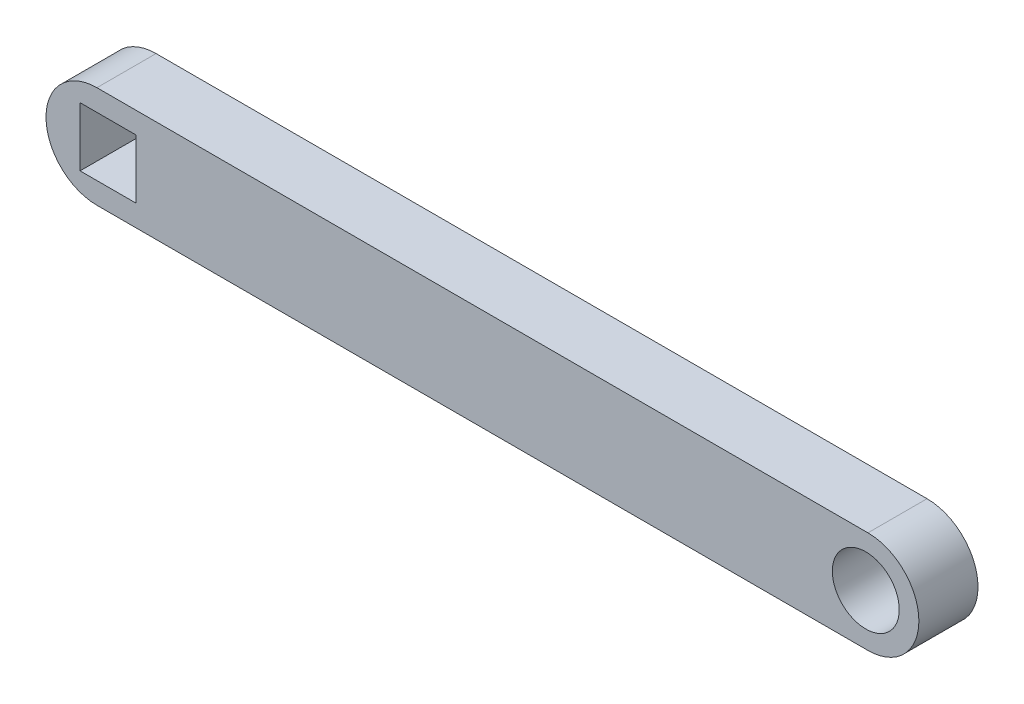
from build123d import *

# Parameters (mm, degrees)
BOSS_EXTRUDE1_DEPTH     = 3.5
SKETCH3_R               = 3.960739879
CUT_EXTRUDE2_DEPTH      = 4.5
CUT_EXTRUDE2_DEPTH_BACK = 4.5
SKETCH4_W               = 6.635737024
SKETCH4_H               = 6.991222936
CUT_EXTRUDE3_DEPTH      = 4.5
CUT_EXTRUDE3_DEPTH_BACK = 4.5
BOSS_EXTRUDE5_START     = 3.5
BOSS_EXTRUDE5_DEPTH     = 2


with BuildPart() as part:
    # Sketch1 → Boss-Extrude1 (new body, symmetric)
    with BuildSketch(Plane.XY):
        with BuildLine():
            Line((-43.599357872, 6.029698429), (47.680999885, 6.029698429))
            ThreePointArc((47.680999885, 6.029698429), (53.710698314, 0), (47.680999885, -6.029698429))
            Line((47.680999885, -6.029698429), (-43.599357872, -6.029698429))
            ThreePointArc((-43.599357872, -6.029698429), (-49.629056301, 0), (-43.599357872, 6.029698429))
        make_face()
    extrude(amount=BOSS_EXTRUDE1_DEPTH, both=True)

    # Sketch3 → Cut-Extrude2 (cut, two sides)
    with BuildSketch(Plane.XY) as cut_extrude2_sk:
        with Locations((47.424522437, 0)):
            Circle(SKETCH3_R)
    extrude(amount=CUT_EXTRUDE2_DEPTH, mode=Mode.SUBTRACT)
    extrude(cut_extrude2_sk.sketch, amount=-CUT_EXTRUDE2_DEPTH_BACK, mode=Mode.SUBTRACT)

    # Sketch4 → Cut-Extrude3 (cut, two sides)
    with BuildSketch(Plane.XY) as cut_extrude3_sk:
        with Locations((-42.276422688, 0)):
            Rectangle(SKETCH4_W, SKETCH4_H)
    extrude(amount=CUT_EXTRUDE3_DEPTH, mode=Mode.SUBTRACT)
    extrude(cut_extrude3_sk.sketch, amount=-CUT_EXTRUDE3_DEPTH_BACK, mode=Mode.SUBTRACT)


with BuildPart() as body_2:
    # Sketch5 → Boss-Extrude5 (new body)
    with BuildSketch(Plane.XY.offset(BOSS_EXTRUDE5_START)):
        with BuildLine():
            Line((-31.019368808, 2.66614434), (36.285963862, 2.66614434))
            ThreePointArc((36.285963862, 2.66614434), (38.952108202, 0), (36.285963862, -2.66614434))
            Line((36.285963862, -2.66614434), (-31.019368808, -2.66614434))
            ThreePointArc((-31.019368808, -2.66614434), (-33.685513148, 0), (-31.019368808, 2.66614434))
        make_face()
    extrude(amount=-BOSS_EXTRUDE5_DEPTH)


solid = Compound([part.part, body_2.part])
